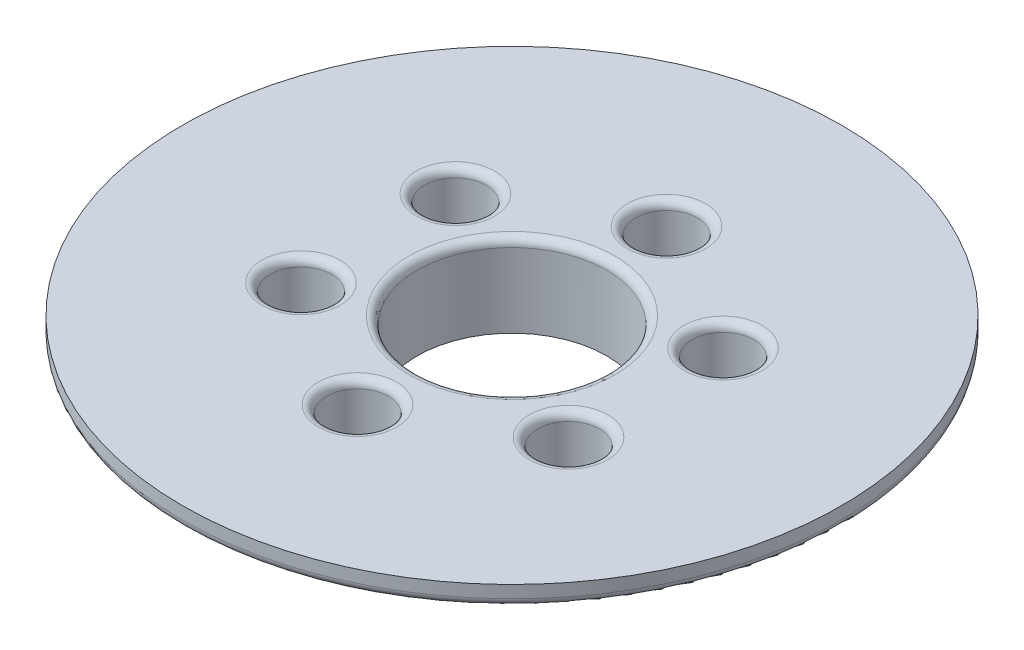
from build123d import *

# Parameters (mm, degrees)
SKETCH1_R           = 31.75
SKETCH1_R_2         = 29.21
BOSS_EXTRUDE1_DEPTH = 3.175
SKETCH2_R           = 31.75
BOSS_EXTRUDE2_DEPTH = 9.525
SKETCH3_R           = 14.605
CUT_EXTRUDE1_DEPTH  = 10.525
SKETCH4_R           = 50.8
SKETCH4_R_2         = 14.605
RIM_DEPTH           = 3.175
SKETCH5_R           = 2.667
CUT_EXTRUDE_R_DEPTH = 13.7
SKETCH6_R           = 4.7625
CUT_EXTRUDE3_DEPTH  = 8.255
FILLET1_R           = 1.27


with BuildPart() as part:
    # Sketch1 → Boss-Extrude1 (new body)
    with BuildSketch(Plane(origin=(0, 0, 0), x_dir=(1, 0, 0), z_dir=(0, 1, 0))):
        Circle(SKETCH1_R)
        Circle(SKETCH1_R_2, mode=Mode.SUBTRACT)
    extrude(amount=BOSS_EXTRUDE1_DEPTH)

    # Sketch2 → Boss-Extrude2 (add)
    with BuildSketch(Plane(origin=(0, 3.175, 0), x_dir=(1, 0, 0), z_dir=(0, 1, 0))):
        Circle(SKETCH2_R)
    extrude(amount=BOSS_EXTRUDE2_DEPTH)

    # Sketch3 → Cut-Extrude1 (cut, through all)
    with BuildSketch(Plane.XZ.offset(-3.175)):
        Circle(SKETCH3_R)
    extrude(amount=-CUT_EXTRUDE1_DEPTH, mode=Mode.SUBTRACT)

    # Sketch4 → Rim (add)
    with BuildSketch(Plane(origin=(0, 12.7, 0), x_dir=(1, 0, 0), z_dir=(0, 1, 0))):
        Circle(SKETCH4_R)
        Circle(SKETCH4_R_2, mode=Mode.SUBTRACT)
    extrude(amount=RIM_DEPTH)

    # Sketch5 → Cut-Extrude r (cut, through all)
    with BuildSketch(Plane.XZ.offset(-3.175)):
        with Locations((0, 23.8125)):
            Circle(SKETCH5_R)
        with Locations((20.622229928, 11.90625)):
            Circle(SKETCH5_R)
        with Locations((20.622229928, -11.90625)):
            Circle(SKETCH5_R)
        with Locations((0, -23.8125)):
            Circle(SKETCH5_R)
        with Locations((-20.622229928, -11.90625)):
            Circle(SKETCH5_R)
        with Locations((-20.622229928, 11.90625)):
            Circle(SKETCH5_R)
    extrude(amount=-CUT_EXTRUDE_R_DEPTH, mode=Mode.SUBTRACT)

    # Sketch6 → Cut-Extrude3 (cut)
    with BuildSketch(Plane(origin=(0, 15.875, 0), x_dir=(1, 0, 0), z_dir=(0, 1, 0))):
        with Locations((20.622229928, -11.90625)):
            Circle(SKETCH6_R)
        with Locations((0, -23.8125)):
            Circle(SKETCH6_R)
        with Locations((-20.622229928, -11.90625)):
            Circle(SKETCH6_R)
        with Locations((-20.622229928, 11.90625)):
            Circle(SKETCH6_R)
        with Locations((0, 23.8125)):
            Circle(SKETCH6_R)
        with Locations((20.622229928, 11.90625)):
            Circle(SKETCH6_R)
    extrude(amount=-CUT_EXTRUDE3_DEPTH, mode=Mode.SUBTRACT)

    # Fillet1
    fillet1_edges = [part.edges().sort_by_distance(p)[0] for p in [
        (-50.8, 12.7, 0),
        (-14.605, 15.875, 0),
        (15.859729928, 15.875, -11.90625),
        (-4.7625, 15.875, -23.8125),
        (-25.384729928, 15.875, -11.90625),
        (-25.384729928, 15.875, 11.90625),
        (-4.7625, 15.875, 23.8125),
        (15.859729928, 15.875, 11.90625),
    ]]
    fillet(fillet1_edges, radius=FILLET1_R)


solid = part.part
